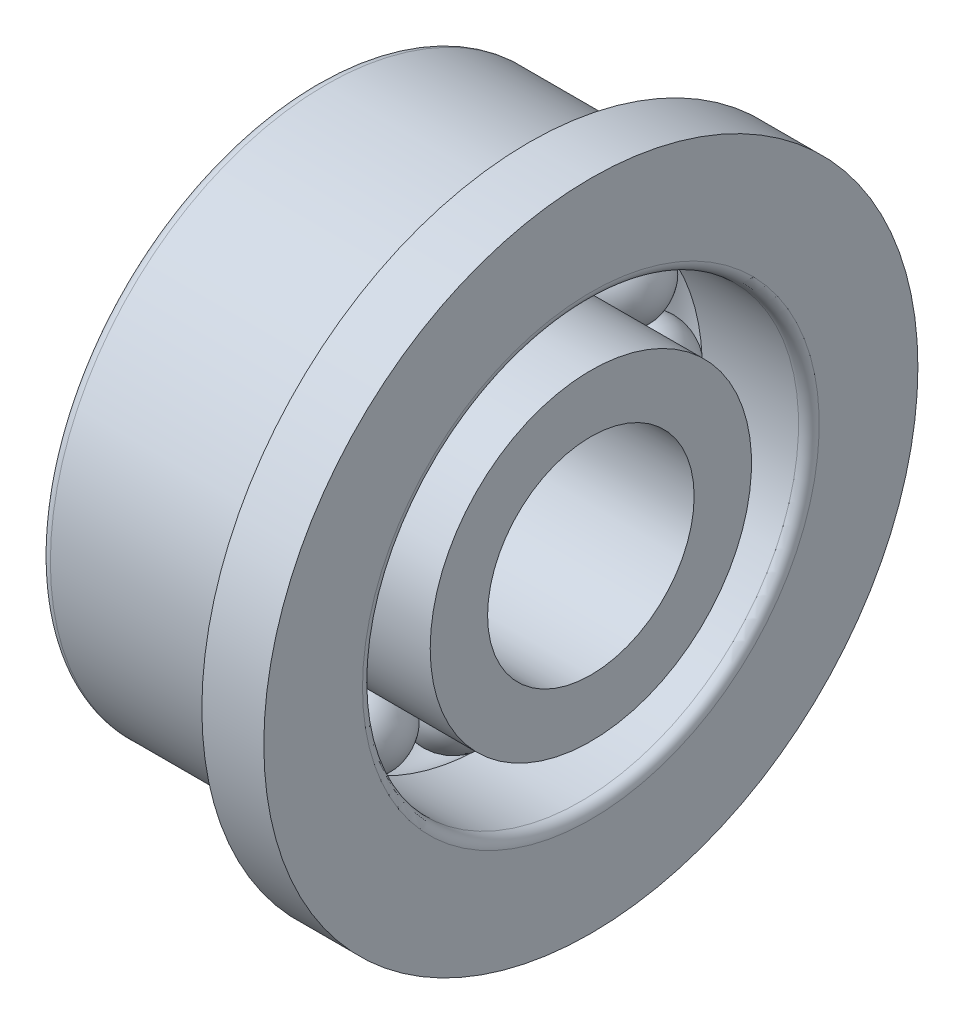
from build123d import *

# Parameters (mm, degrees)
CIRCULAR_PATTERN1_COUNT = 12
FILLET1_R               = 0.15


with BuildPart() as part:
    # Sketch1 → Revolve1 (revolve)
    with BuildSketch(Plane.XY):
        with BuildLine():
            Line((-0.625, 2.75), (0.625, 2.75))
            ThreePointArc((0.625, 2.75), (0, 2.125), (-0.625, 2.75))
        make_face()
    revolve1 = revolve(axis=Axis((-0.807148311, 2.75, 0), (1, 0, 0)))

    # Sketch2 → Revolve2 (revolve)
    with BuildSketch(Plane.XY, mode=Mode.PRIVATE) as revolve2_sk:
        with BuildLine():
            Line((-2, 2.333333333), (-0.452342668, 2.333333333))
            ThreePointArc((-0.452342668, 2.333333333), (0, 2.135), (0.452342668, 2.333333333))
            Line((0.452342668, 2.333333333), (2, 2.333333333))
            Line((2, 2.333333333), (2, 1.5))
            Line((2, 1.5), (-2, 1.5))
            Line((-2, 1.5), (-2, 2.333333333))
        make_face()
    revolve(revolve2_sk.sketch.rotate(Axis((-0.841709544, 0, 0), (1, 0, 0)), 90), axis=Axis((-0.841709544, 0, 0), (1, 0, 0)))

    # Sketch3 → Revolve3 (revolve)
    with BuildSketch(Plane.XY, mode=Mode.PRIVATE) as revolve3_sk:
        with BuildLine():
            Line((-2, 4), (-2, 3.166666667))
            Line((-2, 3.166666667), (-0.452342668, 3.166666667))
            ThreePointArc((-0.452342668, 3.166666667), (0, 3.365), (0.452342668, 3.166666667))
            Line((0.452342668, 3.166666667), (2, 3.166666667))
            Line((2, 3.166666667), (2, 4.75))
            Line((2, 4.75), (1.1, 4.75))
            Line((1.1, 4.75), (1.1, 4.0375))
            ThreePointArc((1.1, 4.0375), (1.126516504, 3.973483496), (1.0625, 4))
            Line((1.0625, 4), (-2, 4))
        make_face()
    revolve(revolve3_sk.sketch.rotate(Axis((-0.999715665, 0, 0), (1, 0, 0)), 90), axis=Axis((-0.999715665, 0, 0), (1, 0, 0)))

    # Circular-Pattern1: Revolve1 ×12 about axis
    circular_pattern1_axis = Axis((0, 0, 0), (1, 0, 0))
    for i in range(1, CIRCULAR_PATTERN1_COUNT):
        add(revolve1.rotate(circular_pattern1_axis, i * 360 / CIRCULAR_PATTERN1_COUNT))

    # Fillet1
    fillet1_edges = [part.edges().sort_by_distance(p)[0] for p in [
        (-2, 0, -4),
        (2, 0, -3.166666667),
        (-2, 0, -1.5),
    ]]
    fillet(fillet1_edges, radius=FILLET1_R)


solid = part.part
